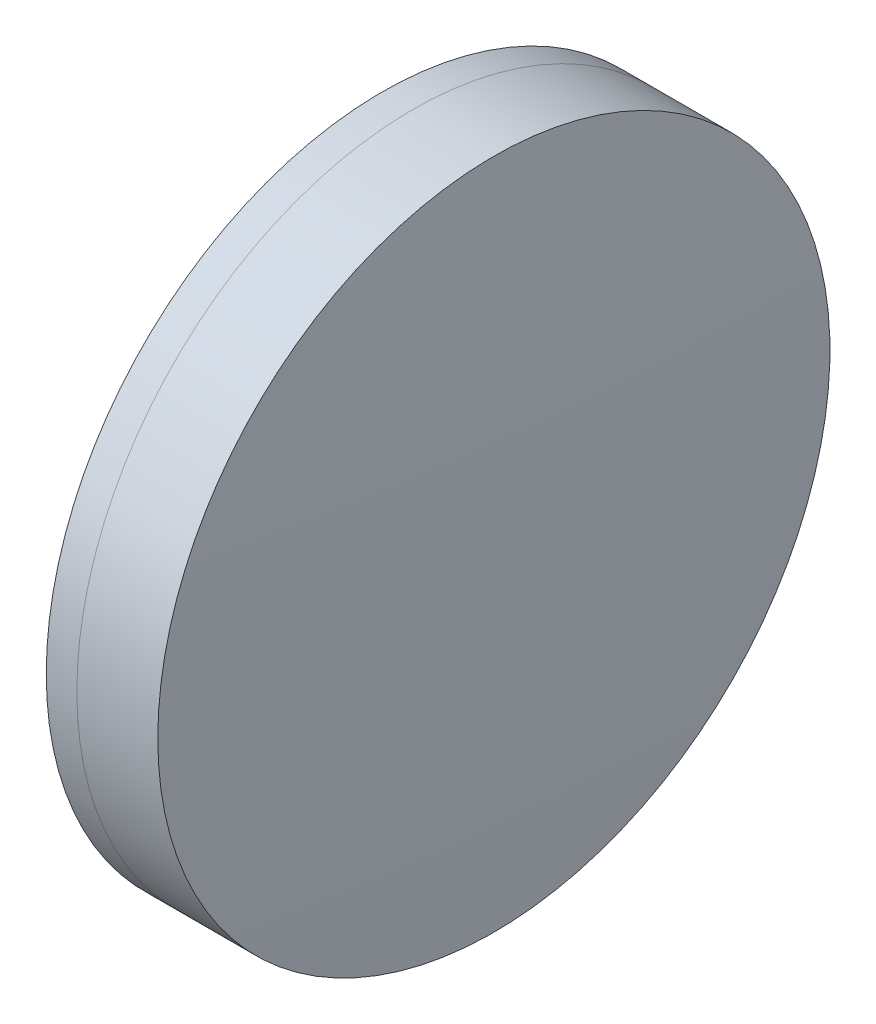
from build123d import *


with BuildPart() as part:
    # 草图1 one side → 旋转1 (revolve)
    with BuildSketch(Plane(origin=(0, 0, 0), x_dir=(1, 0, 0), z_dir=(0, 1, 0)), mode=Mode.PRIVATE) as revolve_1_sk:
        with BuildLine():
            ThreePointArc((234.526529083, 15), (233.308195072, 7.543937436), (232.900500739, 0))
            Line((232.900500739, 0), (237.900500739, 0))
            ThreePointArc((237.900500739, 0), (237.39599514, 7.566975111), (235.891409078, 15))
            Line((235.891409078, 15), (234.526529083, 15))
        make_face()
    revolve(revolve_1_sk.sketch.rotate(Axis((124.523309526, 0, 0), (1, 0, 0)), 180), axis=Axis((124.523309526, 0, 0), (1, 0, 0)))  # turned: the seam where the file's is


with BuildPart() as body_2:
    # 草图2 one side → 旋转3 (revolve)
    with BuildSketch(Plane(origin=(0, 0, 0), x_dir=(1, 0, 0), z_dir=(0, 1, 0)), mode=Mode.PRIVATE) as revolve_3_sk:
        with BuildLine():
            Line((239.504655638, 15), (235.891409078, 15))
            ThreePointArc((235.891409078, 15), (237.39599514, 7.566975111), (237.900500739, 0))
            Line((237.900500739, 0), (239.900500739, 0))
            ThreePointArc((239.900500739, 0), (239.80152224, 7.502611101), (239.504655638, 15))
        make_face()
    revolve(revolve_3_sk.sketch.rotate(Axis((-0.551919993, 0, 0), (1, 0, 0)), 180), axis=Axis((-0.551919993, 0, 0), (1, 0, 0)))  # turned: the seam where the file's is


solid = Compound([part.part, body_2.part])
